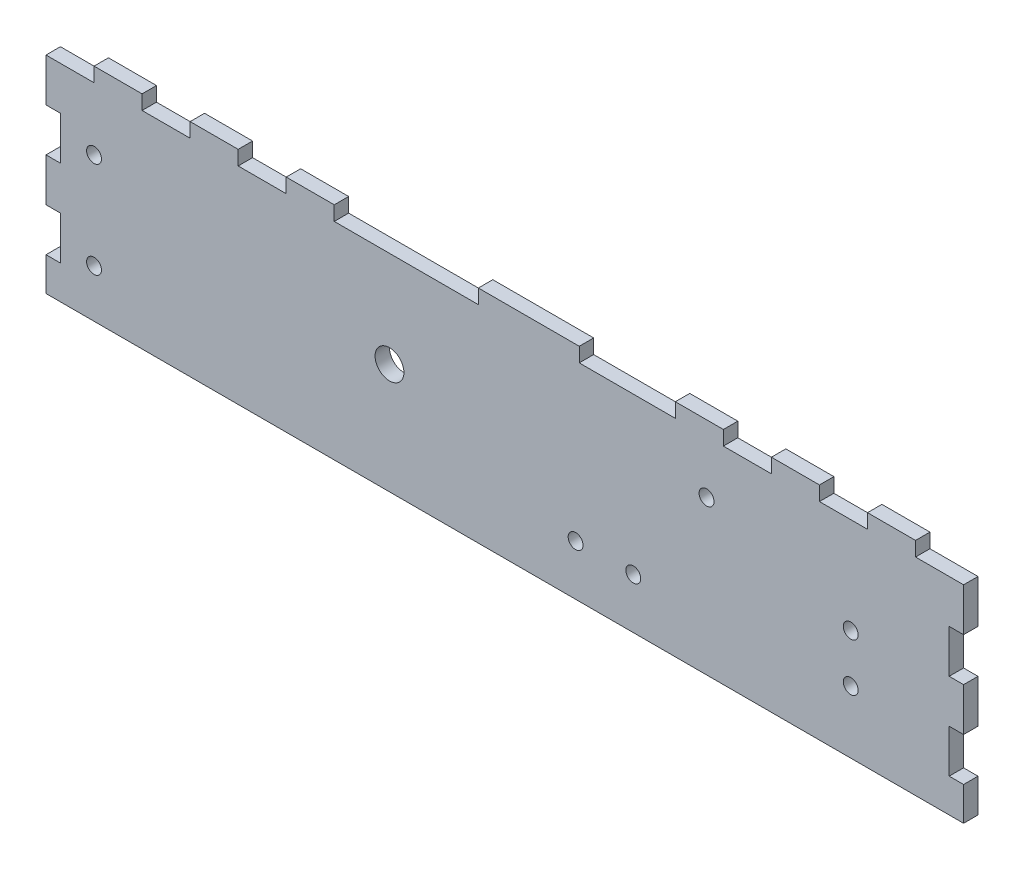
from build123d import *

# Parameters (mm, degrees)
SKETCH1_W           = 191
SKETCH1_H           = 46
SKETCH1_R           = 1.549999948
BOSS_EXTRUDE1_DEPTH = 3
CUT_EXTRUDE1_REACH  = 198.484
SKETCH3_W           = 10
SKETCH3_H           = 3
SKETCH3_W_2         = 30
SKETCH3_W_3         = 20
CUT_EXTRUDE2_REACH  = 198.484
SKETCH4_W           = 3
SKETCH4_H           = 9
CUT_EXTRUDE3_REACH  = 198.484
SKETCH6_R           = 3
CUT_EXTRUDE4_REACH  = 198.484
SKETCH7_R           = 1.55


with BuildPart() as part:
    # Sketch1 → Boss-Extrude1 (new body)
    with BuildSketch(Plane.XY):
        with Locations((-95.5, 23)):
            Rectangle(SKETCH1_W, SKETCH1_H)
        with Locations((-181, 30)):
            Circle(SKETCH1_R, mode=Mode.SUBTRACT)
        with Locations((-181, 10)):
            Circle(SKETCH1_R, mode=Mode.SUBTRACT)
    extrude(amount=BOSS_EXTRUDE1_DEPTH)

    # Sketch3 → Cut-Extrude1 (cut, up to next)
    with BuildSketch(Plane(origin=(0, 0, 0), x_dir=(-1, 0, 0), z_dir=(0, 0, -1)), mode=Mode.PRIVATE) as cut_extrude1_sk1:
        with Locations((45, 44.5)):
            Rectangle(SKETCH3_W, SKETCH3_H)
    cut_extrude1_tool1 = extrude(cut_extrude1_sk1.sketch, amount=-CUT_EXTRUDE1_REACH, mode=Mode.PRIVATE) & part.part
    # Sketch3 → Cut-Extrude1 (cut, up to next)
    with BuildSketch(Plane(origin=(0, 0, 0), x_dir=(-1, 0, 0), z_dir=(0, 0, -1)), mode=Mode.PRIVATE) as cut_extrude1_sk2:
        with Locations((25, 44.5)):
            Rectangle(SKETCH3_W, SKETCH3_H)
    cut_extrude1_tool2 = extrude(cut_extrude1_sk2.sketch, amount=-CUT_EXTRUDE1_REACH, mode=Mode.PRIVATE) & part.part
    # Sketch3 → Cut-Extrude1 (cut, up to next)
    with BuildSketch(Plane(origin=(0, 0, 0), x_dir=(-1, 0, 0), z_dir=(0, 0, -1)), mode=Mode.PRIVATE) as cut_extrude1_sk3:
        with Locations((5, 44.5)):
            Rectangle(SKETCH3_W, SKETCH3_H)
    cut_extrude1_tool3 = extrude(cut_extrude1_sk3.sketch, amount=-CUT_EXTRUDE1_REACH, mode=Mode.PRIVATE) & part.part
    # Sketch3 → Cut-Extrude1 (cut, up to next)
    with BuildSketch(Plane(origin=(0, 0, 0), x_dir=(-1, 0, 0), z_dir=(0, 0, -1)), mode=Mode.PRIVATE) as cut_extrude1_sk4:
        with Locations((166, 44.5)):
            Rectangle(SKETCH3_W, SKETCH3_H)
    cut_extrude1_tool4 = extrude(cut_extrude1_sk4.sketch, amount=-CUT_EXTRUDE1_REACH, mode=Mode.PRIVATE) & part.part
    # Sketch3 → Cut-Extrude1 (cut, up to next)
    with BuildSketch(Plane(origin=(0, 0, 0), x_dir=(-1, 0, 0), z_dir=(0, 0, -1)), mode=Mode.PRIVATE) as cut_extrude1_sk5:
        with Locations((146, 44.5)):
            Rectangle(SKETCH3_W, SKETCH3_H)
    cut_extrude1_tool5 = extrude(cut_extrude1_sk5.sketch, amount=-CUT_EXTRUDE1_REACH, mode=Mode.PRIVATE) & part.part
    # Sketch3 → Cut-Extrude1 (cut, up to next)
    with BuildSketch(Plane(origin=(0, 0, 0), x_dir=(-1, 0, 0), z_dir=(0, 0, -1)), mode=Mode.PRIVATE) as cut_extrude1_sk6:
        with Locations((116, 44.5)):
            Rectangle(SKETCH3_W_2, SKETCH3_H)
    cut_extrude1_tool6 = extrude(cut_extrude1_sk6.sketch, amount=-CUT_EXTRUDE1_REACH, mode=Mode.PRIVATE) & part.part
    # Sketch3 → Cut-Extrude1 (cut, up to next)
    with BuildSketch(Plane(origin=(0, 0, 0), x_dir=(-1, 0, 0), z_dir=(0, 0, -1)), mode=Mode.PRIVATE) as cut_extrude1_sk7:
        with Locations((70, 44.5)):
            Rectangle(SKETCH3_W_3, SKETCH3_H)
    cut_extrude1_tool7 = extrude(cut_extrude1_sk7.sketch, amount=-CUT_EXTRUDE1_REACH, mode=Mode.PRIVATE) & part.part
    # Sketch3 → Cut-Extrude1 (cut, up to next)
    with BuildSketch(Plane(origin=(0, 0, 0), x_dir=(-1, 0, 0), z_dir=(0, 0, -1)), mode=Mode.PRIVATE) as cut_extrude1_sk8:
        with Locations((186, 44.5)):
            Rectangle(SKETCH3_W, SKETCH3_H)
    cut_extrude1_tool8 = extrude(cut_extrude1_sk8.sketch, amount=-CUT_EXTRUDE1_REACH, mode=Mode.PRIVATE) & part.part
    add(cut_extrude1_tool1.solids().sort_by_distance((-45, 44.5, 0))[0], mode=Mode.SUBTRACT)
    add(cut_extrude1_tool2.solids().sort_by_distance((-25, 44.5, 0))[0], mode=Mode.SUBTRACT)
    add(cut_extrude1_tool3.solids().sort_by_distance((-5, 44.5, 0))[0], mode=Mode.SUBTRACT)
    add(cut_extrude1_tool4.solids().sort_by_distance((-166, 44.5, 0))[0], mode=Mode.SUBTRACT)
    add(cut_extrude1_tool5.solids().sort_by_distance((-146, 44.5, 0))[0], mode=Mode.SUBTRACT)
    add(cut_extrude1_tool6.solids().sort_by_distance((-116, 44.5, 0))[0], mode=Mode.SUBTRACT)
    add(cut_extrude1_tool7.solids().sort_by_distance((-70, 44.5, 0))[0], mode=Mode.SUBTRACT)
    add(cut_extrude1_tool8.solids().sort_by_distance((-186, 44.5, 0))[0], mode=Mode.SUBTRACT)

    # Sketch4 → Cut-Extrude2 (cut, up to next)
    with BuildSketch(Plane.XY.offset(3), mode=Mode.PRIVATE) as cut_extrude2_sk1:
        with Locations((-1.5, 29.5)):
            Rectangle(SKETCH4_W, SKETCH4_H)
    cut_extrude2_tool1 = extrude(cut_extrude2_sk1.sketch, amount=-CUT_EXTRUDE2_REACH, mode=Mode.PRIVATE) & part.part
    # Sketch4 → Cut-Extrude2 (cut, up to next)
    with BuildSketch(Plane.XY.offset(3), mode=Mode.PRIVATE) as cut_extrude2_sk2:
        with Locations((-1.5, 11.5)):
            Rectangle(SKETCH4_W, SKETCH4_H)
    cut_extrude2_tool2 = extrude(cut_extrude2_sk2.sketch, amount=-CUT_EXTRUDE2_REACH, mode=Mode.PRIVATE) & part.part
    cut_extrude2_1 = cut_extrude2_tool1.solids().sort_by_distance((-1.5, 29.5, 3))[0]
    add(cut_extrude2_1, mode=Mode.SUBTRACT)
    cut_extrude2_2 = cut_extrude2_tool2.solids().sort_by_distance((-1.5, 11.5, 3))[0]
    add(cut_extrude2_2, mode=Mode.SUBTRACT)
    cut_extrude2 = cut_extrude2_1 + cut_extrude2_2  # Cut-Extrude2 as one shape, for the pattern or mirror that repeats it

    # Mirror1: Cut-Extrude2 across plane
    add(cut_extrude2.mirror(Plane(origin=(-95.5, 0, 0), x_dir=(0, 0, 1), z_dir=(1, 0, 0))), mode=Mode.SUBTRACT)

    # Sketch6 → Cut-Extrude3 (cut, up to next)
    with BuildSketch(Plane.XY.offset(3), mode=Mode.PRIVATE) as cut_extrude3_sk1:
        with Locations((-119.5, 23)):
            Circle(SKETCH6_R)
    cut_extrude3_tool1 = extrude(cut_extrude3_sk1.sketch, amount=-CUT_EXTRUDE3_REACH, mode=Mode.PRIVATE) & part.part
    add(cut_extrude3_tool1.solids().sort_by_distance((-119.5, 23, 3))[0], mode=Mode.SUBTRACT)

    # Sketch7 → Cut-Extrude4 (cut, up to next)
    with BuildSketch(Plane.XY.offset(3), mode=Mode.PRIVATE) as cut_extrude4_sk1:
        with Locations((-53.5, 32)):
            Circle(SKETCH7_R)
    cut_extrude4_tool1 = extrude(cut_extrude4_sk1.sketch, amount=-CUT_EXTRUDE4_REACH, mode=Mode.PRIVATE) & part.part
    # Sketch7 → Cut-Extrude4 (cut, up to next)
    with BuildSketch(Plane.XY.offset(3), mode=Mode.PRIVATE) as cut_extrude4_sk2:
        with Locations((-68.757359313, 10.5)):
            Circle(SKETCH7_R)
    cut_extrude4_tool2 = extrude(cut_extrude4_sk2.sketch, amount=-CUT_EXTRUDE4_REACH, mode=Mode.PRIVATE) & part.part
    # Sketch7 → Cut-Extrude4 (cut, up to next)
    with BuildSketch(Plane.XY.offset(3), mode=Mode.PRIVATE) as cut_extrude4_sk3:
        with Locations((-80.757359313, 10.5)):
            Circle(SKETCH7_R)
    cut_extrude4_tool3 = extrude(cut_extrude4_sk3.sketch, amount=-CUT_EXTRUDE4_REACH, mode=Mode.PRIVATE) & part.part
    # Sketch7 → Cut-Extrude4 (cut, up to next)
    with BuildSketch(Plane.XY.offset(3), mode=Mode.PRIVATE) as cut_extrude4_sk4:
        with Locations((-23.5, 23)):
            Circle(SKETCH7_R)
    cut_extrude4_tool4 = extrude(cut_extrude4_sk4.sketch, amount=-CUT_EXTRUDE4_REACH, mode=Mode.PRIVATE) & part.part
    # Sketch7 → Cut-Extrude4 (cut, up to next)
    with BuildSketch(Plane.XY.offset(3), mode=Mode.PRIVATE) as cut_extrude4_sk5:
        with Locations((-23.5, 13)):
            Circle(SKETCH7_R)
    cut_extrude4_tool5 = extrude(cut_extrude4_sk5.sketch, amount=-CUT_EXTRUDE4_REACH, mode=Mode.PRIVATE) & part.part
    add(cut_extrude4_tool1.solids().sort_by_distance((-53.5, 32, 3))[0], mode=Mode.SUBTRACT)
    add(cut_extrude4_tool2.solids().sort_by_distance((-68.757359, 10.5, 3))[0], mode=Mode.SUBTRACT)
    add(cut_extrude4_tool3.solids().sort_by_distance((-80.757359, 10.5, 3))[0], mode=Mode.SUBTRACT)
    add(cut_extrude4_tool4.solids().sort_by_distance((-23.5, 23, 3))[0], mode=Mode.SUBTRACT)
    add(cut_extrude4_tool5.solids().sort_by_distance((-23.5, 13, 3))[0], mode=Mode.SUBTRACT)


solid = part.part
